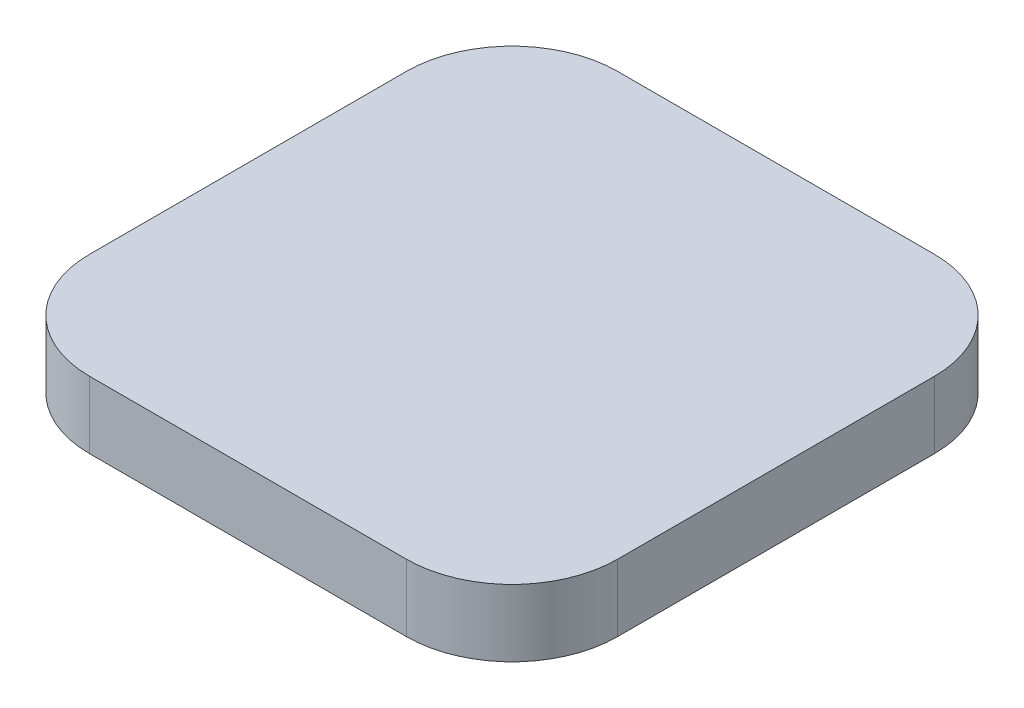
from build123d import *

# Parameters (mm, degrees)
SKETCH1_W           = 25
SKETCH1_H           = 25
BOSS_EXTRUDE1_DEPTH = 3.175
FILLET1_R           = 5


with BuildPart() as part:
    # Sketch1 → Boss-Extrude1 (new body)
    with BuildSketch(Plane(origin=(0, 0, 0), x_dir=(1, 0, 0), z_dir=(0, 1, 0))):
        with Locations((12.5, -12.5)):
            Rectangle(SKETCH1_W, SKETCH1_H)
    extrude(amount=BOSS_EXTRUDE1_DEPTH)

    # Fillet1
    fillet1_edges = [part.edges().sort_by_distance(p)[0] for p in [
        (0, 1.5875, 0),
        (25, 1.5875, 0),
        (25, 1.5875, 25),
        (0, 1.5875, 25),
    ]]
    fillet(fillet1_edges, radius=FILLET1_R)


solid = part.part
